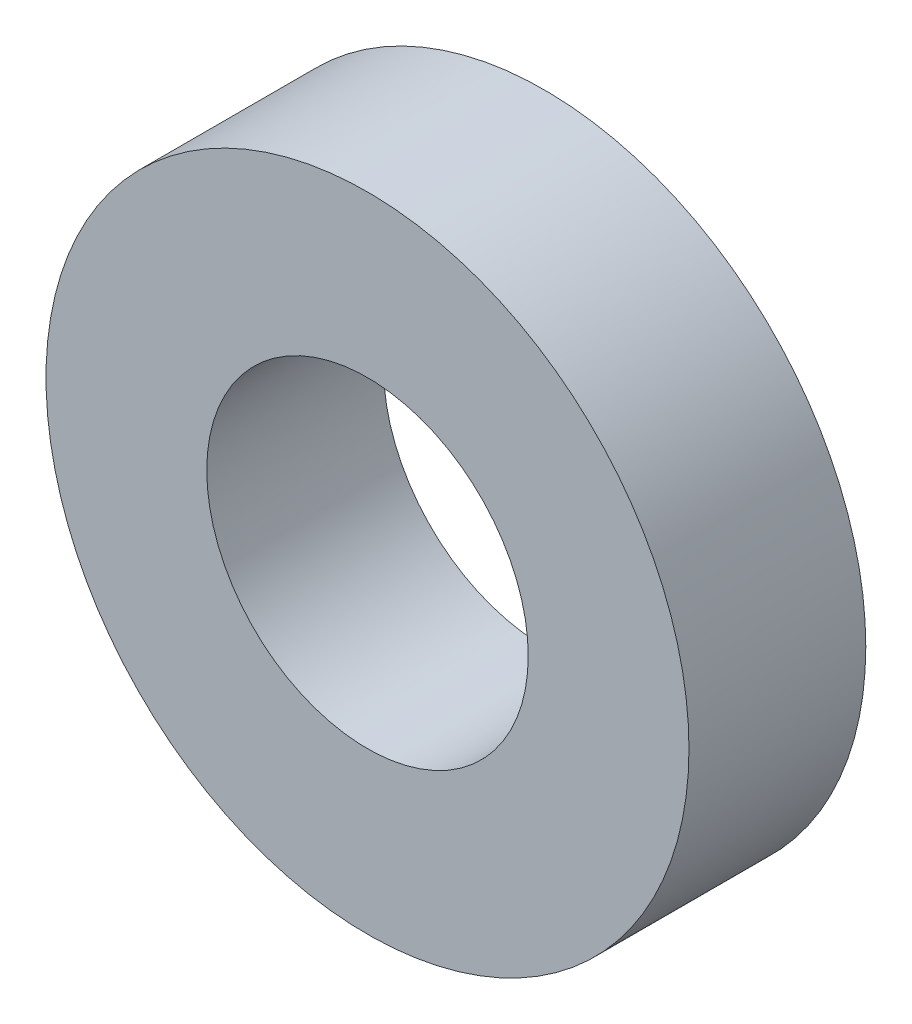
from build123d import *

# Parameters (mm, degrees)
SKETCH1_R           = 20
SKETCH1_R_2         = 10
BOSS_EXTRUDE1_DEPTH = 11


with BuildPart() as part:
    # Sketch1 → Boss-Extrude1 (new body)
    with BuildSketch(Plane.XY):
        Circle(SKETCH1_R)
        Circle(SKETCH1_R_2, mode=Mode.SUBTRACT)
    extrude(amount=BOSS_EXTRUDE1_DEPTH)


solid = part.part
